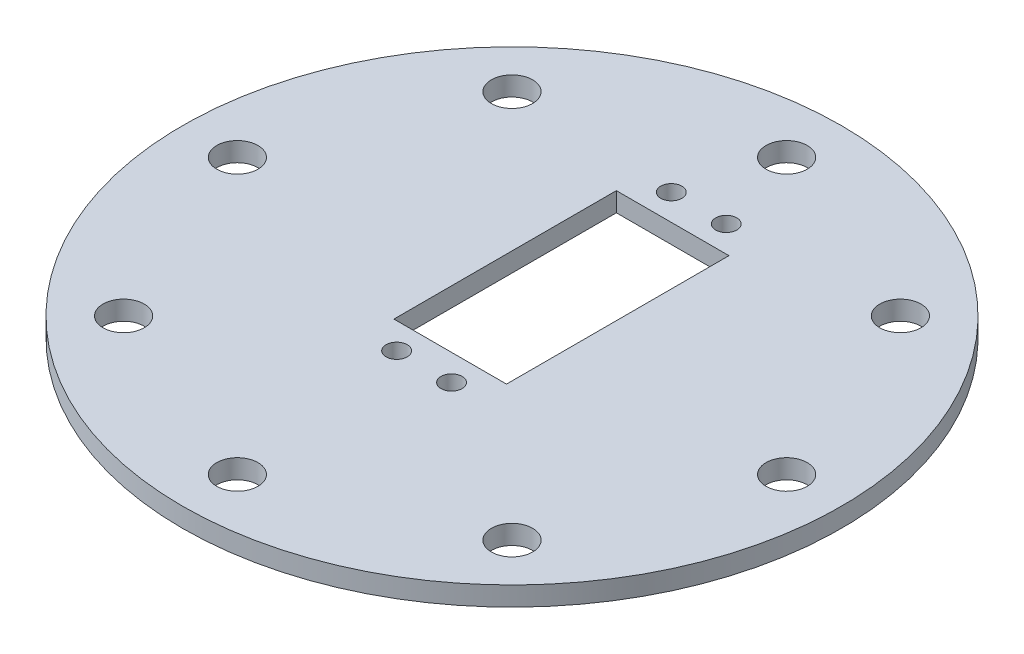
from build123d import *

# Parameters (mm, degrees)
CROQUIS1_R              = 60
SALIENTE_EXTRUIR1_DEPTH = 3.5
CROQUIS2_R              = 3.75
CORTAR_EXTRUIR1_DEPTH   = 3.5
MATRIZC1_COUNT          = 8
CORTAR_EXTRUIR3_REACH   = 5.5
CROQUIS4_R              = 1.92644479
CORTAR_EXTRUIR4_REACH   = 5.5
CROQUIS5_W              = 20.5
CROQUIS5_H              = 40.5


with BuildPart() as part:
    # Croquis1 → Saliente-Extruir1 (new body)
    with BuildSketch(Plane(origin=(0, 0, 0), x_dir=(1, 0, 0), z_dir=(0, 1, 0))):
        Circle(CROQUIS1_R)
    extrude(amount=SALIENTE_EXTRUIR1_DEPTH)

    # Croquis2 → Cortar-Extruir1 (cut)
    with BuildSketch(Plane(origin=(0, 3.5, 0), x_dir=(1, 0, 0), z_dir=(0, 1, 0))):
        with Locations((0, 50)):
            Circle(CROQUIS2_R)
    cortar_extruir1 = extrude(amount=-CORTAR_EXTRUIR1_DEPTH, mode=Mode.SUBTRACT)

    # MatrizC1: Cortar-Extruir1 ×8 about axis
    matrizc1_axis = Axis((0, 0, 0), (0, 1, 0))
    for i in range(1, MATRIZC1_COUNT):
        add(cortar_extruir1.rotate(matrizc1_axis, i * 360 / MATRIZC1_COUNT), mode=Mode.SUBTRACT)

    # Croquis4 → Cortar-Extruir3 (cut, up to next)
    with BuildSketch(Plane(origin=(0, 3.5, 0), x_dir=(1, 0, 0), z_dir=(0, 1, 0)), mode=Mode.PRIVATE) as cortar_extruir3_sk1:
        with Locations((5, 34)):
            Circle(CROQUIS4_R)
    cortar_extruir3_tool1 = extrude(cortar_extruir3_sk1.sketch, amount=-CORTAR_EXTRUIR3_REACH, mode=Mode.PRIVATE) & part.part
    add(cortar_extruir3_tool1.solids().sort_by_distance((5, 3.5, -34))[0], mode=Mode.SUBTRACT)
    # Croquis4 → Cortar-Extruir3 (cut, up to next)
    with BuildSketch(Plane(origin=(0, 3.5, 0), x_dir=(1, 0, 0), z_dir=(0, 1, 0)), mode=Mode.PRIVATE) as cortar_extruir3_sk2:
        with Locations((5, -16)):
            Circle(CROQUIS4_R)
    cortar_extruir3_tool2 = extrude(cortar_extruir3_sk2.sketch, amount=-CORTAR_EXTRUIR3_REACH, mode=Mode.PRIVATE) & part.part
    add(cortar_extruir3_tool2.solids().sort_by_distance((5, 3.5, 16))[0], mode=Mode.SUBTRACT)
    # Croquis4 → Cortar-Extruir3 (cut, up to next)
    with BuildSketch(Plane(origin=(0, 3.5, 0), x_dir=(1, 0, 0), z_dir=(0, 1, 0)), mode=Mode.PRIVATE) as cortar_extruir3_sk3:
        with Locations((-5, 34)):
            Circle(CROQUIS4_R)
    cortar_extruir3_tool3 = extrude(cortar_extruir3_sk3.sketch, amount=-CORTAR_EXTRUIR3_REACH, mode=Mode.PRIVATE) & part.part
    add(cortar_extruir3_tool3.solids().sort_by_distance((-5, 3.5, -34))[0], mode=Mode.SUBTRACT)
    # Croquis4 → Cortar-Extruir3 (cut, up to next)
    with BuildSketch(Plane(origin=(0, 3.5, 0), x_dir=(1, 0, 0), z_dir=(0, 1, 0)), mode=Mode.PRIVATE) as cortar_extruir3_sk4:
        with Locations((-5, -16)):
            Circle(CROQUIS4_R)
    cortar_extruir3_tool4 = extrude(cortar_extruir3_sk4.sketch, amount=-CORTAR_EXTRUIR3_REACH, mode=Mode.PRIVATE) & part.part
    add(cortar_extruir3_tool4.solids().sort_by_distance((-5, 3.5, 16))[0], mode=Mode.SUBTRACT)

    # Croquis5 → Cortar-Extruir4 (cut, up to next)
    with BuildSketch(Plane(origin=(0, 3.5, 0), x_dir=(1, 0, 0), z_dir=(0, 1, 0)), mode=Mode.PRIVATE) as cortar_extruir4_sk1:
        with Locations((0, 9)):
            Rectangle(CROQUIS5_W, CROQUIS5_H)
    cortar_extruir4_tool1 = extrude(cortar_extruir4_sk1.sketch, amount=-CORTAR_EXTRUIR4_REACH, mode=Mode.PRIVATE) & part.part
    add(cortar_extruir4_tool1.solids().sort_by_distance((0, 3.5, -9))[0], mode=Mode.SUBTRACT)


solid = part.part
